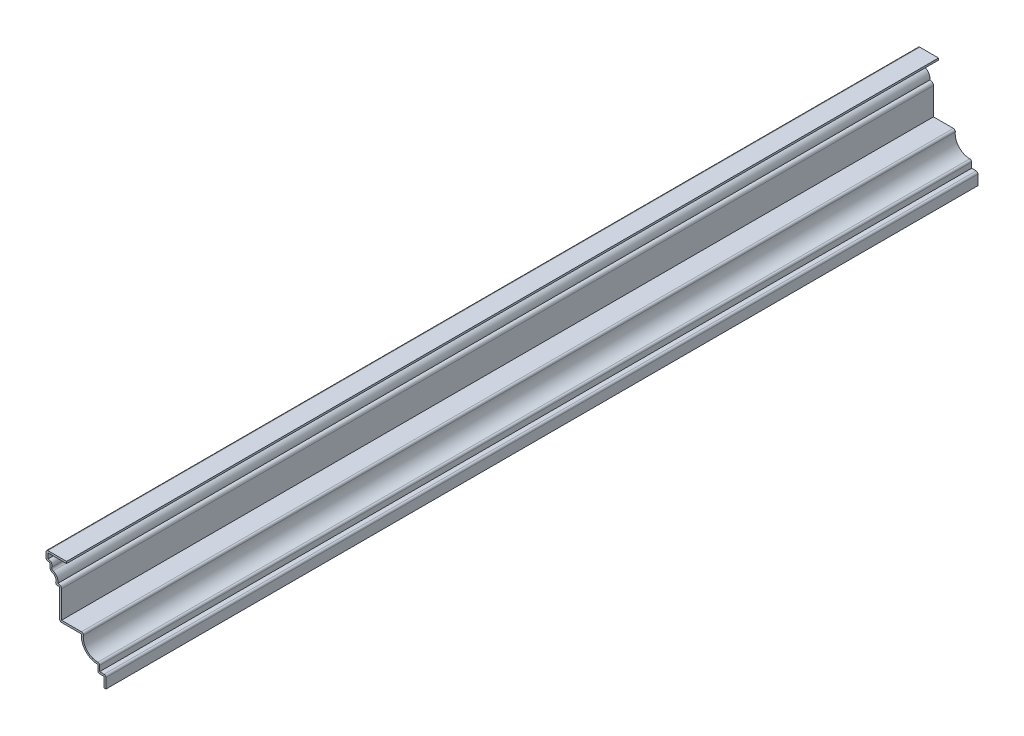
from build123d import *

# Parameters (mm, degrees)
EXTRUDE_THIN1_DEPTH = 762
FILLET1_R           = 1.651


with BuildPart() as part:
    # Sketch1 → Extrude-Thin1 (new body)
    with BuildSketch(Plane.XY):
        with BuildLine():
            Line((0, 0), (0, 8.73125))
            Line((0, 8.73125), (-5.55625, 8.73125))
            Line((-5.55625, 8.73125), (-5.55625, 15.08125))
            ThreePointArc((-5.55625, 15.08125), (-16.235064, 19.837192), (-19.84375, 30.95625))
            Line((-19.84375, 30.95625), (-38.89375, 30.95625))
            Line((-38.89375, 30.95625), (-38.89375, 56.35625))
            ThreePointArc((-38.89375, 56.35625), (-39.341606, 57.151515), (-40.253834, 57.180844))
            ThreePointArc((-40.253834, 57.180844), (-41.798306, 57.35168), (-42.225966, 58.845562))
            ThreePointArc((-42.225966, 58.845562), (-42.493091, 62.371576), (-45.152095, 64.702632))
            ThreePointArc((-45.152095, 64.702632), (-47.13073, 66.482003), (-47.230922, 69.14116))
            ThreePointArc((-47.230922, 69.14116), (-47.420593, 70.70524), (-48.815625, 71.4375))
            Line((-48.815625, 71.4375), (-50.8, 71.4375))
            Line((-50.8, 71.4375), (-50.8, 79.375))
            Line((-50.8, 79.375), (-32.823706, 79.375))
            Line((-32.823706, 79.375), (-32.823706, 77.724))
            Line((-32.823706, 77.724), (-49.149, 77.724))
            Line((-49.149, 77.724), (-49.149, 73.0885))
            Line((-49.149, 73.0885), (-48.815625, 73.0885))
            ThreePointArc((-48.815625, 73.0885), (-46.061751, 71.642976), (-45.68733, 68.555392))
            ThreePointArc((-45.68733, 68.555392), (-45.635593, 67.182265), (-44.613871, 66.263439))
            ThreePointArc((-44.613871, 66.263439), (-41.137974, 63.341171), (-40.514728, 58.843051))
            ThreePointArc((-40.514728, 58.843051), (-38.261995, 58.411123), (-37.24275, 56.35625))
            Line((-37.24275, 56.35625), (-37.24275, 32.60725))
            Line((-37.24275, 32.60725), (-17.87345, 32.60725))
            ThreePointArc((-17.87345, 32.60725), (-15.074359, 21.016098), (-3.90525, 16.839887))
            Line((-3.90525, 16.839887), (-3.90525, 10.38225))
            Line((-3.90525, 10.38225), (1.651, 10.38225))
            Line((1.651, 10.38225), (1.651, 0))
            Line((1.651, 0), (0, 0))
        make_face()
    extrude(amount=-EXTRUDE_THIN1_DEPTH)

    # Fillet1
    fillet1_edges = [part.edges().sort_by_distance(p)[0] for p in [
        (-17.87345, 32.60725, -381),
        (-3.90525, 16.839887, -381),
        (1.651, 10.38225, -381),
        (-5.55625, 8.73125, -381),
        (-38.89375, 30.95625, -381),
        (-50.8, 71.4375, -381),
        (-50.8, 79.375, -381),
    ]]
    fillet(fillet1_edges, radius=FILLET1_R)


solid = part.part
